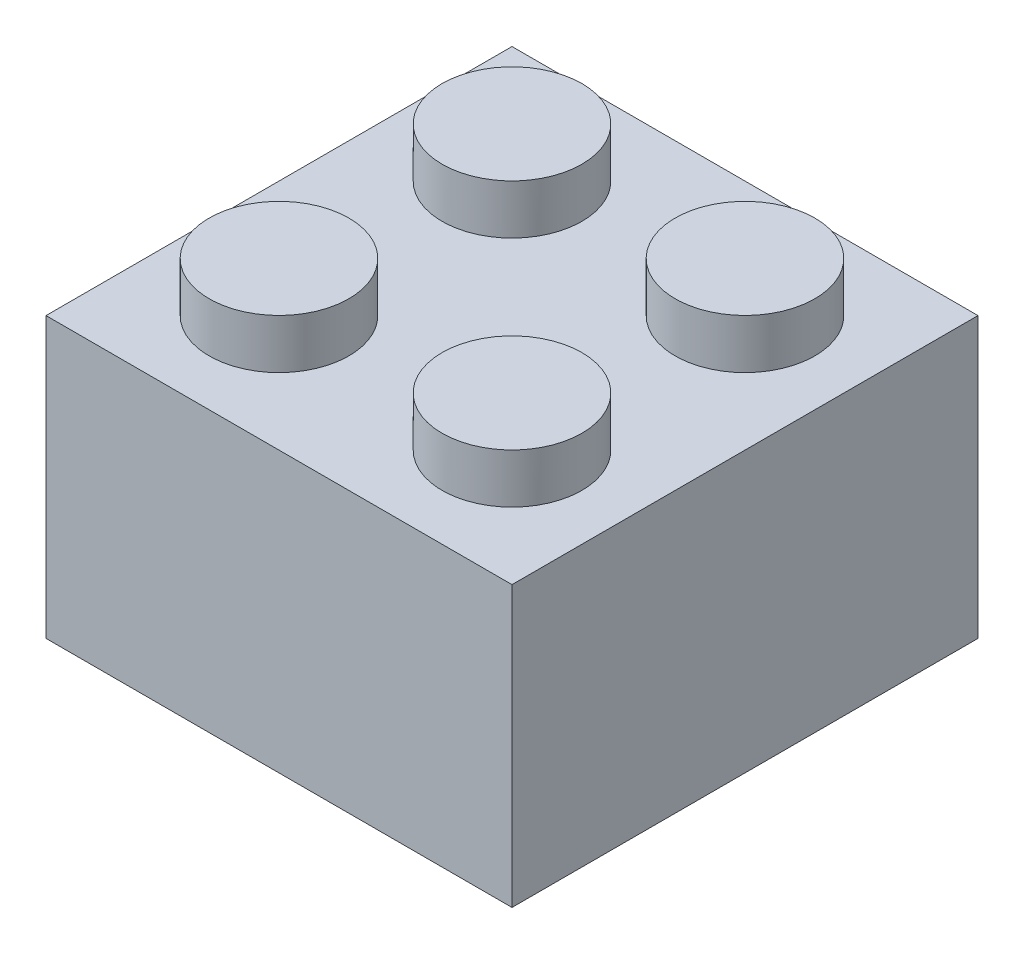
from build123d import *

# Parameters (mm, degrees)
SKETCH_1_W      = 16
SKETCH_1_H      = 16
HEIGHT_DEPTH    = 9.6
SKETCH_2_R      = 2.4
EXTRUDE_2_DEPTH = 1.7
SHELL_1_T       = -1.6
SKETCH_3_R      = 3.255
SKETCH_3_R_2    = 2.4
EXTRUDE_3_DEPTH = 8


with BuildPart() as part:
    # 草圖1 → height (new body)
    with BuildSketch(Plane(origin=(0, 0, 0), x_dir=(1, 0, 0), z_dir=(0, 1, 0))):
        Rectangle(SKETCH_1_W, SKETCH_1_H)
    extrude(amount=HEIGHT_DEPTH)

    # 草圖2 → 填料-伸長2 (add)
    with BuildSketch(Plane(origin=(0, 9.6, 0), x_dir=(1, 0, 0), z_dir=(0, 1, 0))):
        with Locations((-4, 4)):
            Circle(SKETCH_2_R)
        with Locations((4, 4)):
            Circle(SKETCH_2_R)
        with Locations((4, -4)):
            Circle(SKETCH_2_R)
        with Locations((-4, -4)):
            Circle(SKETCH_2_R)
    extrude(amount=EXTRUDE_2_DEPTH)

    # 薄殼1
    shell_1_openings = [part.faces().sort_by_distance(p)[0] for p in [
        (0, 0, 0),
    ]]
    offset(amount=SHELL_1_T, openings=shell_1_openings, kind=Kind.INTERSECTION)

    # 草圖3 → 填料-伸長3 (add)
    with BuildSketch(Plane.XZ.offset(-8)):
        Circle(SKETCH_3_R)
        Circle(SKETCH_3_R_2, mode=Mode.SUBTRACT)
    extrude(amount=EXTRUDE_3_DEPTH)


solid = part.part
